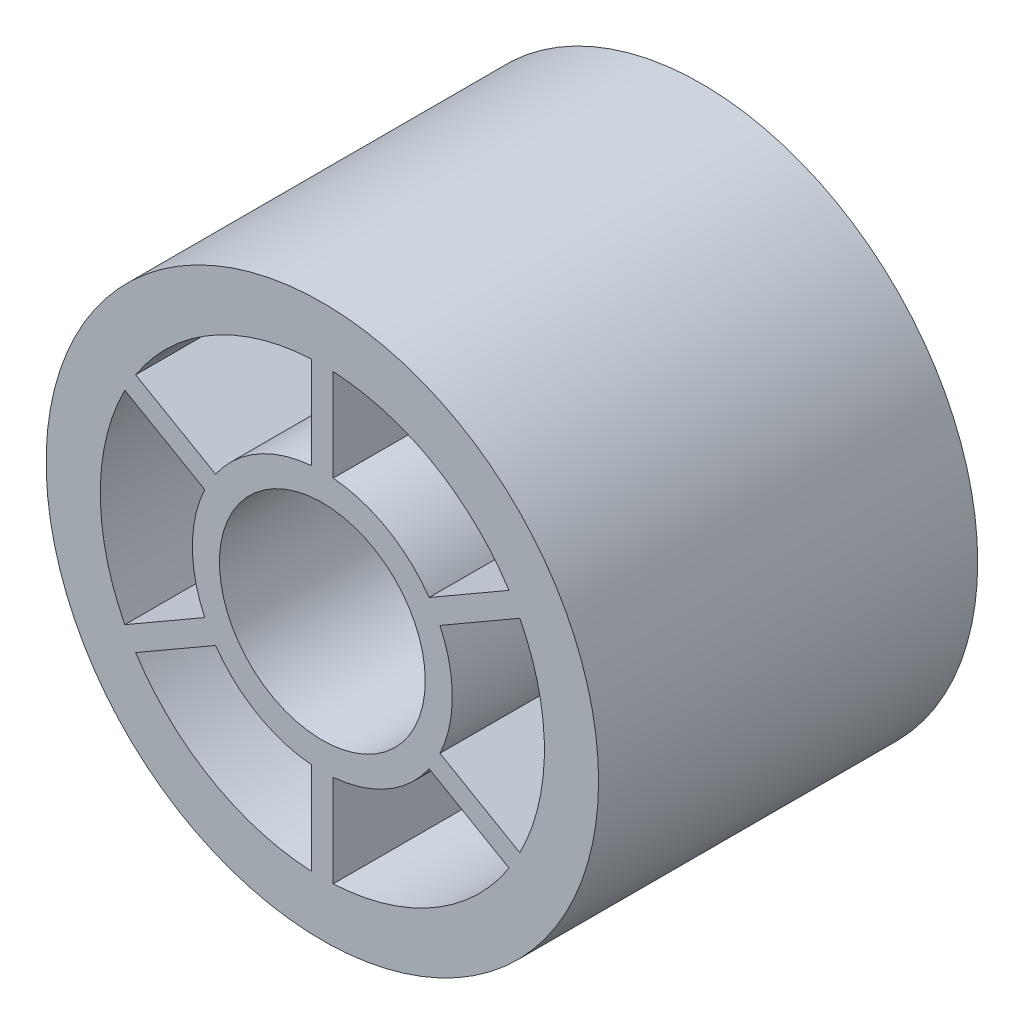
from build123d import *

# Parameters (mm, degrees)
ESQUISSE1_R      = 25.5
ESQUISSE1_R_2    = 9.5
EXTRUSION1_DEPTH = 35


with BuildPart() as part:
    # Esquisse1 → Extrusion1 (new body)
    with BuildSketch(Plane.XY):
        Circle(ESQUISSE1_R)
        Circle(ESQUISSE1_R_2, mode=Mode.SUBTRACT)
        with BuildLine():
            Line((10.856157589, 5.113104968), (18.232385626, 9.371772211))
            ThreePointArc((18.232385626, 9.371772211), (20.5, 0), (18.232385626, -9.371772211))
            Line((18.232385626, -9.371772211), (10.856157589, -5.113104968))
            ThreePointArc((10.856157589, -5.113104968), (12, 0), (10.856157589, 5.113104968))
        make_face(mode=Mode.SUBTRACT)
        with BuildLine():
            Line((9.856157589, 6.845155775), (17.232385626, 11.103823019))
            ThreePointArc((17.232385626, 11.103823019), (10.25, 17.753520778), (1, 20.475595229))
            Line((1, 20.475595229), (1, 11.958260743))
            ThreePointArc((1, 11.958260743), (6, 10.392304845), (9.856157589, 6.845155775))
        make_face(mode=Mode.SUBTRACT)
        with BuildLine():
            Line((9.856157589, -6.845155775), (17.232385626, -11.103823019))
            ThreePointArc((17.232385626, -11.103823019), (10.25, -17.753520778), (1, -20.475595229))
            Line((1, -20.475595229), (1, -11.958260743))
            ThreePointArc((1, -11.958260743), (6, -10.392304845), (9.856157589, -6.845155775))
        make_face(mode=Mode.SUBTRACT)
        with BuildLine():
            Line((-1, 11.958260743), (-1, 20.475595229))
            ThreePointArc((-1, 20.475595229), (-10.25, 17.753520778), (-17.232385626, 11.103823019))
            Line((-17.232385626, 11.103823019), (-9.856157589, 6.845155775))
            ThreePointArc((-9.856157589, 6.845155775), (-6, 10.392304845), (-1, 11.958260743))
        make_face(mode=Mode.SUBTRACT)
        with BuildLine():
            Line((-1, -11.958260743), (-1, -20.475595229))
            ThreePointArc((-1, -20.475595229), (-10.25, -17.753520778), (-17.232385626, -11.103823019))
            Line((-17.232385626, -11.103823019), (-9.856157589, -6.845155775))
            ThreePointArc((-9.856157589, -6.845155775), (-6, -10.392304845), (-1, -11.958260743))
        make_face(mode=Mode.SUBTRACT)
        with BuildLine():
            Line((-10.856157589, -5.113104968), (-18.232385626, -9.371772211))
            ThreePointArc((-18.232385626, -9.371772211), (-20.5, 0), (-18.232385626, 9.371772211))
            Line((-18.232385626, 9.371772211), (-10.856157589, 5.113104968))
            ThreePointArc((-10.856157589, 5.113104968), (-12, 0), (-10.856157589, -5.113104968))
        make_face(mode=Mode.SUBTRACT)
    extrude(amount=EXTRUSION1_DEPTH)


solid = part.part
